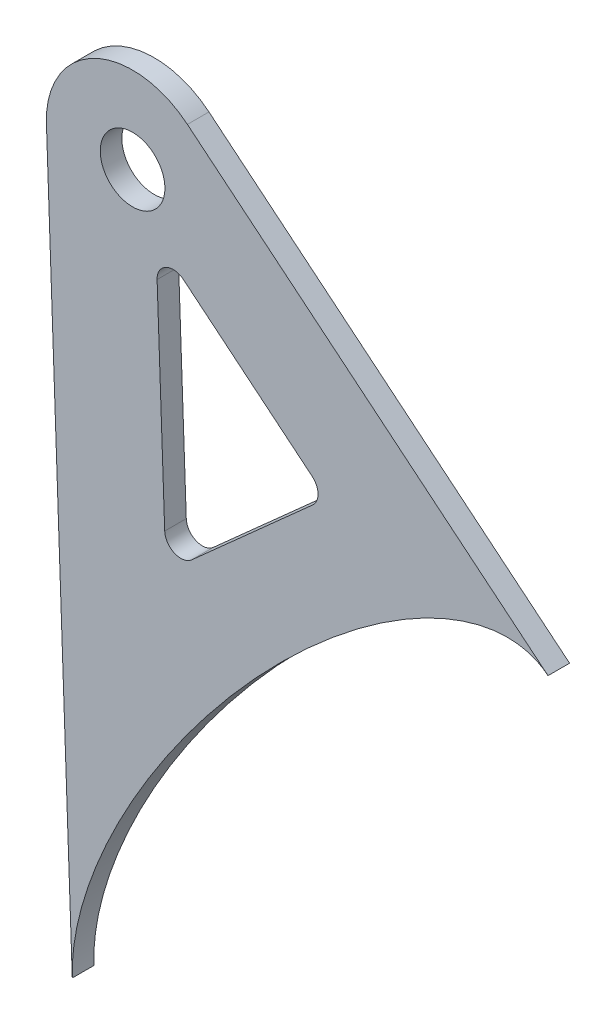
from build123d import *

# Parameters (mm, degrees)
SZKIC1_R                    = 3
DODANIE_WYCI_GNI_CIE1_DEPTH = 2


with BuildPart() as part:
    # Szkic1 → Dodanie-wyciągnięcie1 (new body)
    with BuildSketch(Plane.XY.offset(432.28)):
        with BuildLine():
            Line((1352.005050304, -200.284217104), (1354.40386943, -267.762345401))
            add(Edge.make_bspline(
                [(1354.40386943, -267.762345401), (1353.432452758, -240.436659155), (1386.537067568, -211.615049683), (1398.527258098, -221.376205912), (1398.534359902, -221.381987456), (1398.541447396, -221.387791883), (1398.548520531, -221.39361923)],
                knots=[0.085287538, 0.085287538, 0.085287538, 0.085287538, 0.5, 0.5, 0.5, 0.500549055, 0.500549055, 0.500549055, 0.500549055], degree=3, weights=[0.71704156, 0.352730571, 0.447050051, 1, 0.999267927, 0.998536659, 0.997806194]))
            Line((1398.548520531, -221.39361923), (1365.086912411, -193.825591355))
            ThreePointArc((1365.086912411, -193.825591355), (1356.458442171, -192.82662087), (1352.005050304, -200.284217104))
        make_face()
        with Locations((1360, -200)):
            Circle(SZKIC1_R, mode=Mode.SUBTRACT)
        with BuildLine():
            Line((1364.727751429, -206.486395657), (1376.663408593, -216.319830088))
            ThreePointArc((1376.663408593, -216.319830088), (1377.209316374, -217.447726709), (1376.708653422, -218.596422797))
            Line((1376.708653422, -218.596422797), (1365.479018228, -228.62319398))
            ThreePointArc((1365.479018228, -228.62319398), (1363.891437533, -228.884020586), (1362.980924254, -227.557593599))
            Line((1362.980924254, -227.557593599), (1362.274902284, -207.697387985))
            ThreePointArc((1362.274902284, -207.697387985), (1363.109913259, -206.299088691), (1364.727751429, -206.486395657))
        make_face(mode=Mode.SUBTRACT)
    extrude(amount=DODANIE_WYCI_GNI_CIE1_DEPTH)


solid = part.part
